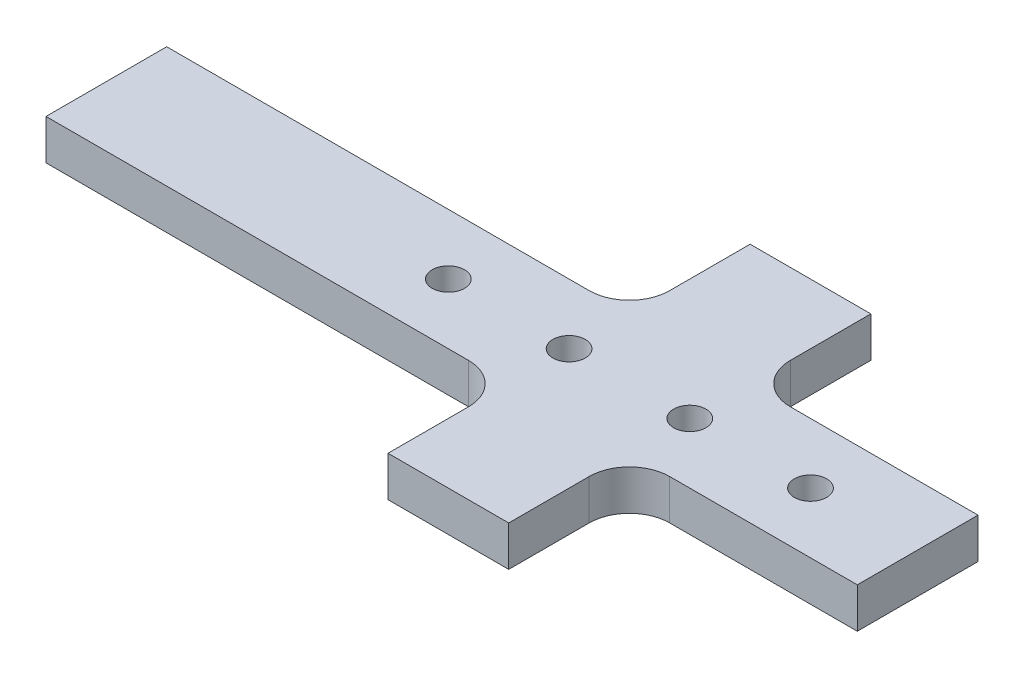
from build123d import *

# Parameters (mm, degrees)
BOSS_EXTRUDE1_DEPTH     = 6.35
F_1_4_20_TAPPED_HOLE1_D = 5.1054
LPATTERN1_COUNT         = 4
LPATTERN1_PITCH         = 19.05


with BuildPart() as part:
    # Sketch1 → Boss-Extrude1 (new body)
    with BuildSketch(Plane(origin=(0, 0, 0), x_dir=(1, 0, 0), z_dir=(0, 1, 0))):
        with BuildLine():
            Line((-74.82695853, -9.525), (-15.875, -9.525))
            ThreePointArc((-15.875, -9.525), (-11.384871939, -11.384871939), (-9.525, -15.875))
            Line((-9.525, -15.875), (-9.525, -28.575))
            Line((-9.525, -28.575), (9.525, -28.575))
            Line((9.525, -28.575), (9.525, -15.875))
            ThreePointArc((9.525, -15.875), (11.384871939, -11.384871939), (15.875, -9.525))
            Line((15.875, -9.525), (45.485511374, -9.525))
            Line((45.485511374, -9.525), (45.485511374, 9.525))
            Line((45.485511374, 9.525), (15.875, 9.525))
            ThreePointArc((15.875, 9.525), (11.384871939, 11.384871939), (9.525, 15.875))
            Line((9.525, 15.875), (9.525, 28.575))
            Line((9.525, 28.575), (-9.525, 28.575))
            Line((-9.525, 28.575), (-9.525, 15.875))
            ThreePointArc((-9.525, 15.875), (-11.384871939, 11.384871939), (-15.875, 9.525))
            Line((-15.875, 9.525), (-75.059577466, 9.525))
            Line((-75.059577466, 9.525), (-82.55, 9.525))
            Line((-82.55, 9.525), (-82.55, -9.525))
            Line((-82.55, -9.525), (-74.82695853, -9.525))
        make_face()
    extrude(amount=BOSS_EXTRUDE1_DEPTH)

    # 1/4-20 Tapped Hole1 (through all)
    with Locations(Plane(origin=(0, 0, 0), x_dir=(-1, 0, 0), z_dir=(0, -1, 0))):
        with Locations((28.575, 0)):
            f_1_4_20_tapped_hole1 = Hole(F_1_4_20_TAPPED_HOLE1_D / 2)

    # LPattern1: 1/4-20 Tapped Hole1 ×4
    with Locations(*[(i * LPATTERN1_PITCH, 0, 0) for i in range(1, LPATTERN1_COUNT)]):
        add(f_1_4_20_tapped_hole1, mode=Mode.SUBTRACT)


solid = part.part
